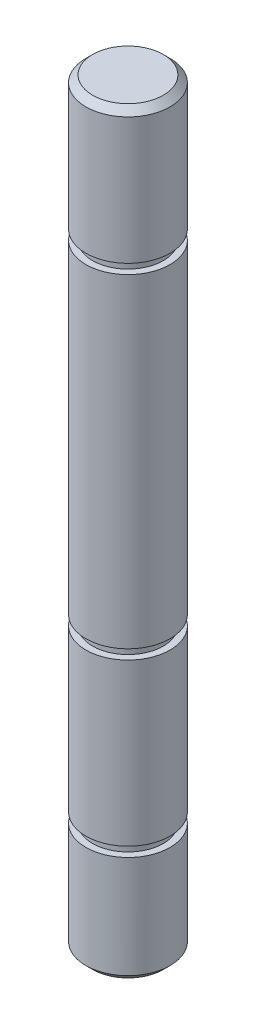
from build123d import *

# Parameters (mm, degrees)
CHAMFER1_SIZE = 0.508


with BuildPart() as part:
    # Sketch1 → Revolve1 (revolve)
    with BuildSketch(Plane.XY):
        Polygon((-3.175, 47.0723), (-3.175, 57.15), (0, 57.15), (0, 0), (-3.175, 0), (-3.175, 8.2357), (-2.667, 8.2357), (-2.667, 8.9723), (-3.175, 8.9723), (-3.175, 21.1389), (-2.667, 21.1389), (-2.667, 21.8755), (-3.175, 21.8755), (-3.175, 46.3357), (-2.667, 46.3357), (-2.667, 47.0723), align=None)
    revolve(axis=Axis((0, 0, 0), (0, -1, 0)))

    # Chamfer1
    chamfer1_edges = [part.edges().sort_by_distance(p)[0] for p in [
        (3.175, 0, 0),
        (3.175, 57.15, 0),
    ]]
    chamfer(chamfer1_edges, length=CHAMFER1_SIZE)


solid = part.part
